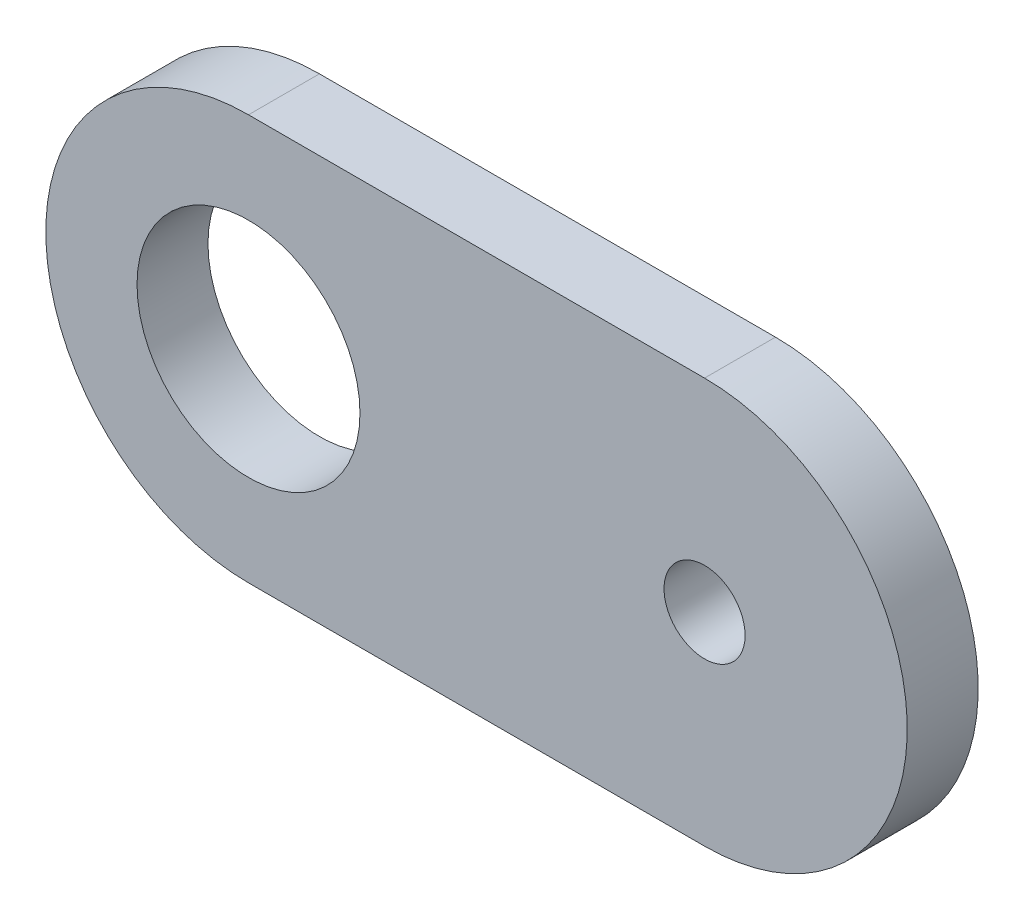
from build123d import *

# Parameters (mm, degrees)
BOSS_EXTRUDE1_DEPTH = 7
SKETCH4_R           = 11
CUT_EXTRUDE1_DEPTH  = 8
SKETCH7_R           = 4
CUT_EXTRUDE2_DEPTH  = 8


with BuildPart() as part:
    # Sketch2 → Boss-Extrude1 (new body)
    with BuildSketch(Plane.XY):
        with BuildLine():
            Line((0, 0), (45, 0))
            ThreePointArc((45, 0), (65, 20), (45, 40))
            Line((45, 40), (0, 40))
            ThreePointArc((0, 40), (-20, 20), (0, 0))
        make_face()
    extrude(amount=BOSS_EXTRUDE1_DEPTH)

    # Sketch4 → Cut-Extrude1 (cut, through all)
    with BuildSketch(Plane(origin=(0, 0, 0), x_dir=(-1, 0, 0), z_dir=(0, 0, -1))):
        with Locations((0, 20)):
            Circle(SKETCH4_R)
    extrude(amount=-CUT_EXTRUDE1_DEPTH, mode=Mode.SUBTRACT)

    # Sketch7 → Cut-Extrude2 (cut, through all)
    with BuildSketch(Plane.XY.offset(7)):
        with Locations((45, 20)):
            Circle(SKETCH7_R)
    extrude(amount=-CUT_EXTRUDE2_DEPTH, mode=Mode.SUBTRACT)


solid = part.part
